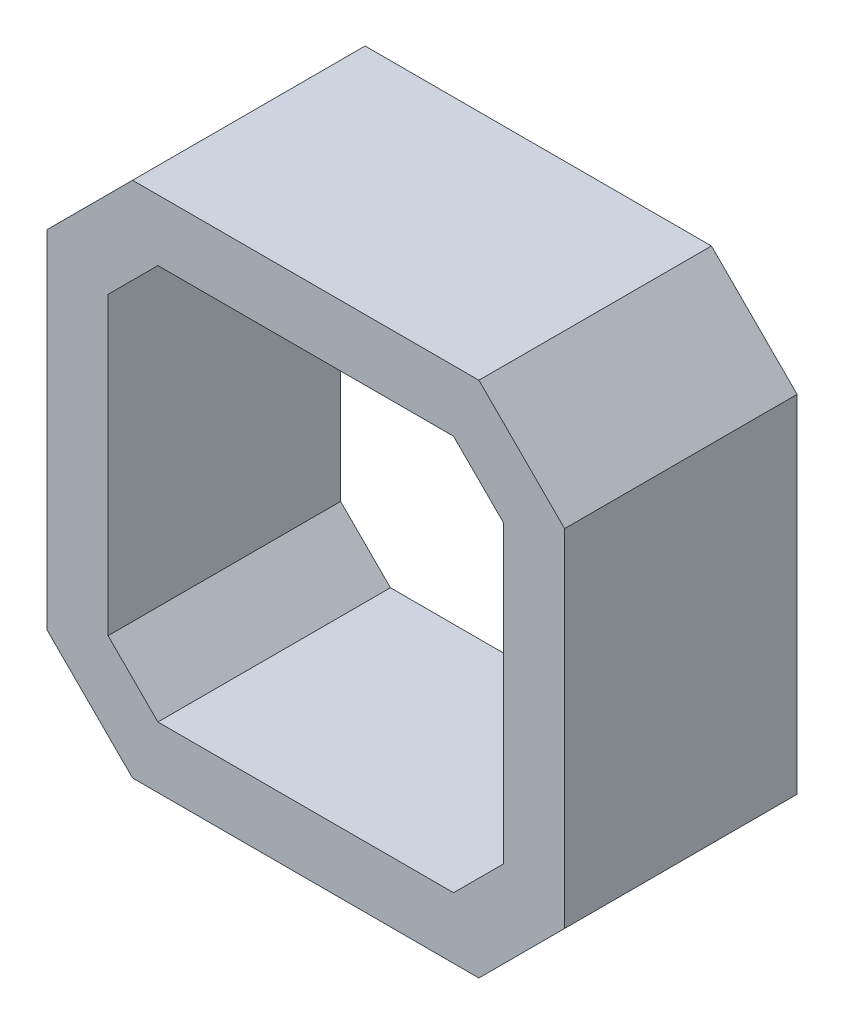
from build123d import *

# Parameters (mm, degrees)
BOSS_EXTRUDE1_DEPTH = 19


with BuildPart() as part:
    # Sketch1 → Boss-Extrude1 (new body)
    with BuildSketch(Plane.XY):
        Polygon((-21.15, 14.15), (-14.15, 21.15), (14.15, 21.15), (21.15, 14.15), (21.15, -14.15), (14.15, -21.15), (-14.15, -21.15), (-21.15, -14.15), align=None)
        Polygon((-12.078932188, 16.15), (12.078932188, 16.15), (16.15, 12.078932188), (16.15, -12.078932188), (12.078932188, -16.15), (-12.078932188, -16.15), (-16.15, -12.078932188), (-16.15, 12.078932188), align=None, mode=Mode.SUBTRACT)
    extrude(amount=BOSS_EXTRUDE1_DEPTH)


solid = part.part
